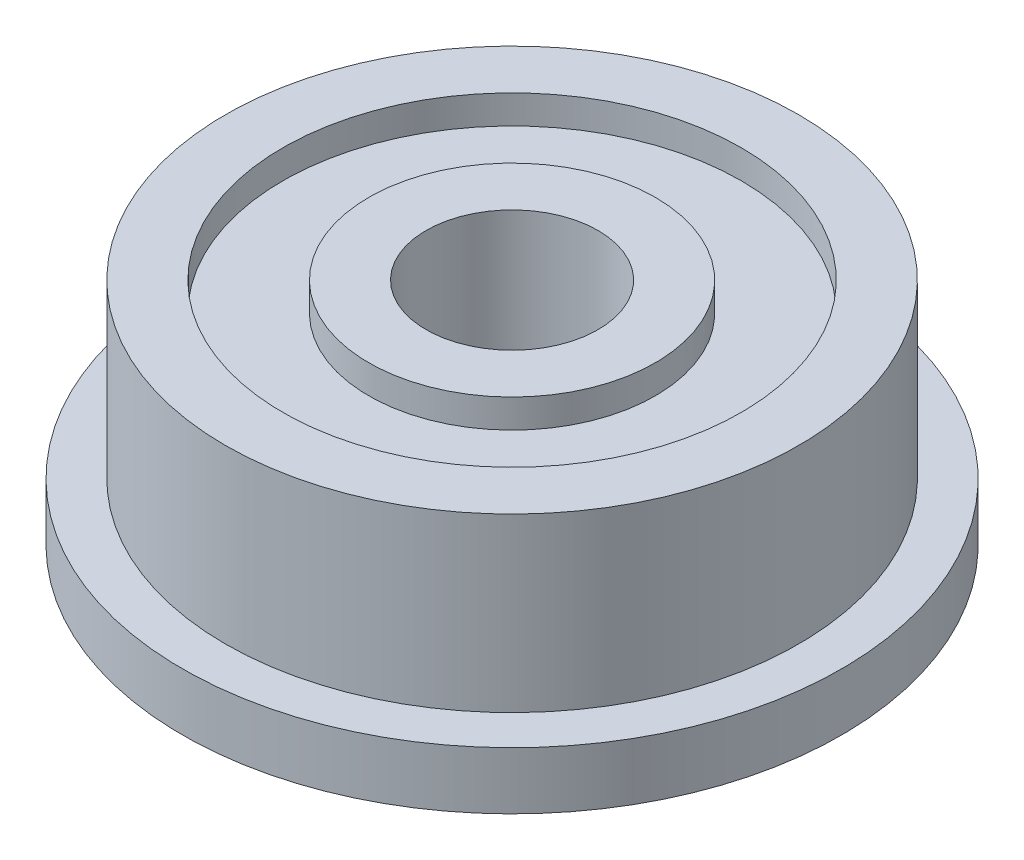
from build123d import *


with BuildPart() as part:
    # Sketch1 → Revolve1 (revolve)
    with BuildSketch(Plane.XY):
        Polygon((1.5, 0), (1.5, 4), (2.5, 4), (2.5, 3.5), (4, 3.5), (4, 4), (5, 4), (5, 1), (5.75, 1), (5.75, 0), (4, 0), (4, 0.5), (2.5, 0.5), (2.5, 0), align=None)
    revolve(axis=Axis((0, -20.797495302, 0), (0, 1, 0)))


solid = part.part
